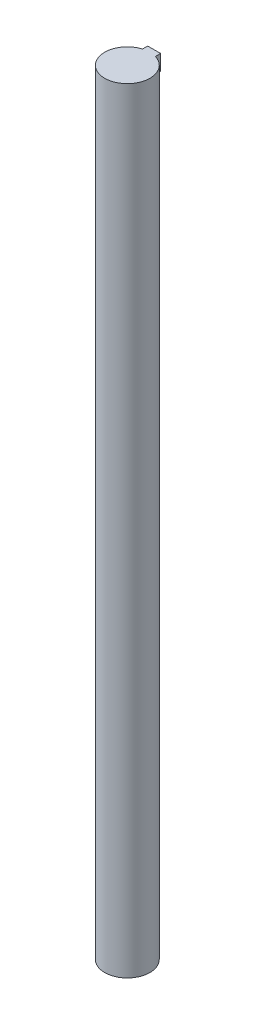
from build123d import *

# Parameters (mm, degrees)
SKETCH1_R           = 17.5
BOSS_EXTRUDE1_DEPTH = 600
SKETCH5_W           = 10
SKETCH5_H           = 4.03
BOSS_EXTRUDE2_DEPTH = 12


with BuildPart() as part:
    # Sketch1 → Boss-Extrude1 (new body)
    with BuildSketch(Plane(origin=(0, 0, 0), x_dir=(1, 0, 0), z_dir=(0, 1, 0))):
        Circle(SKETCH1_R)
    extrude(amount=BOSS_EXTRUDE1_DEPTH)

    # Sketch5 → Boss-Extrude2 (add)
    with BuildSketch(Plane(origin=(0, 600, 0), x_dir=(1, 0, 0), z_dir=(0, 1, 0))):
        with Locations((0, 18.78551)):
            Rectangle(SKETCH5_W, SKETCH5_H)
    extrude(amount=-BOSS_EXTRUDE2_DEPTH)


solid = part.part
